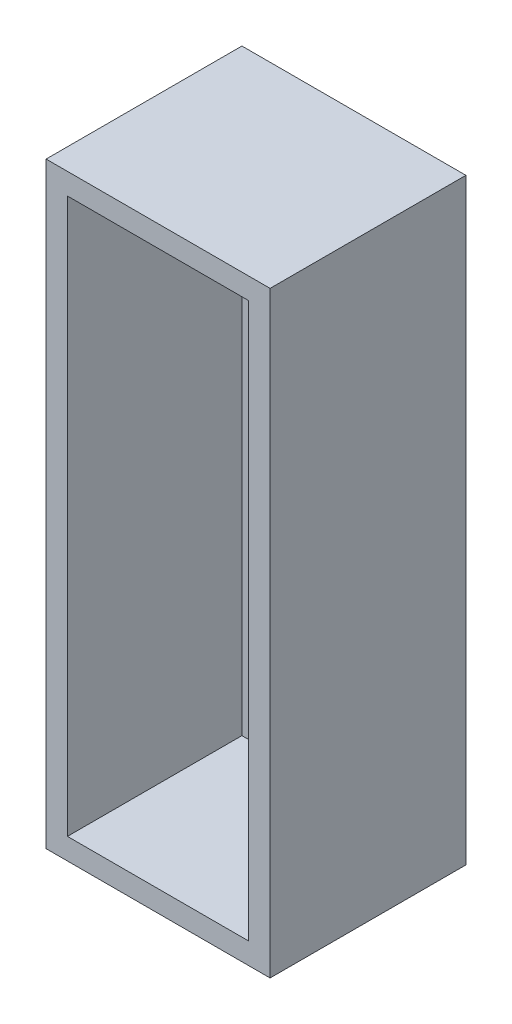
from build123d import *

# Parameters (mm, degrees)
SKETCH1_W           = 133.35
SKETCH1_H           = 355.6
BOSS_EXTRUDE1_DEPTH = 12.7
SKETCH1_3_W         = 133.35
SKETCH1_3_H         = 355.6
SKETCH1_3_W_2       = 107.95
SKETCH1_3_H_2       = 330.2
BOSS_EXTRUDE2_DEPTH = 116.586


with BuildPart() as part:
    # Sketch1 → Boss-Extrude1 (new body)
    with BuildSketch(Plane.XY):
        with Locations((53.975, 165.1)):
            Rectangle(SKETCH1_W, SKETCH1_H)
    extrude(amount=BOSS_EXTRUDE1_DEPTH)

    # Sketch1_3 → Boss-Extrude2 (add)
    with BuildSketch(Plane.XY):
        with Locations((53.975, 165.1)):
            Rectangle(SKETCH1_3_W, SKETCH1_3_H)
        with Locations((53.975, 165.1)):
            Rectangle(SKETCH1_3_W_2, SKETCH1_3_H_2, mode=Mode.SUBTRACT)
    extrude(amount=BOSS_EXTRUDE2_DEPTH)


solid = part.part
